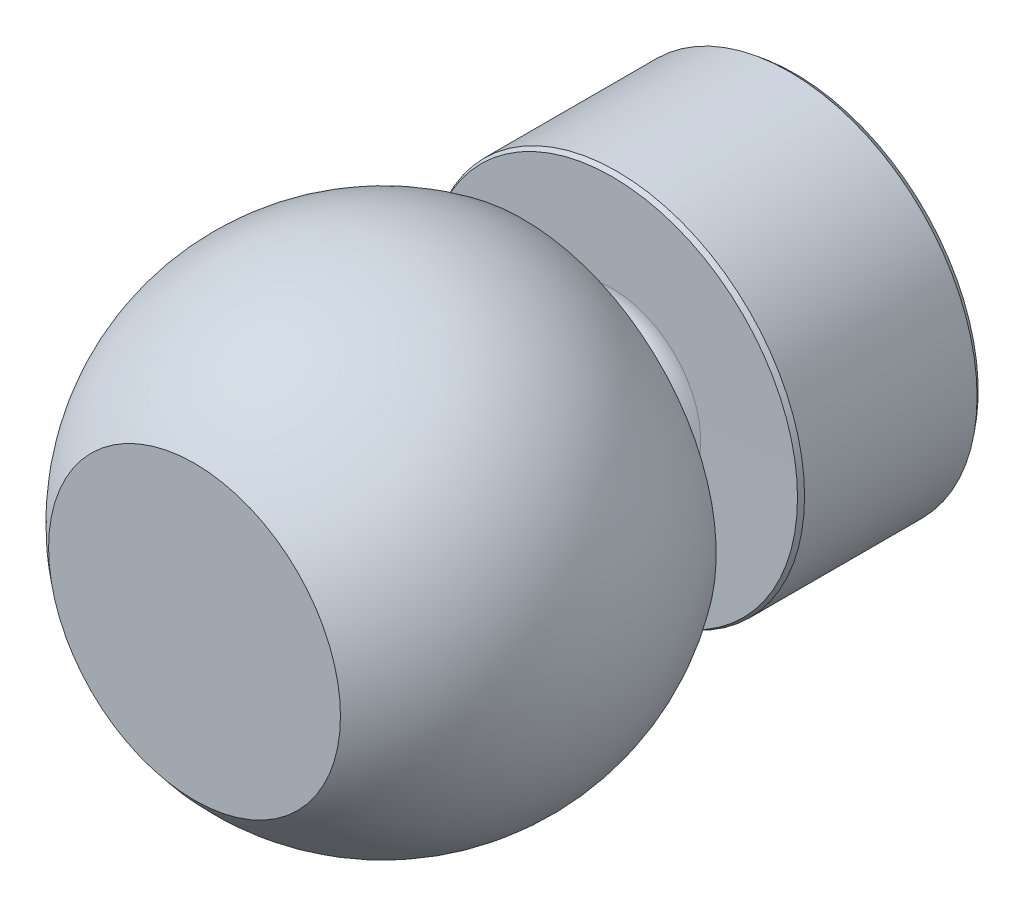
from build123d import *


with BuildPart() as part:
    # Sketch1 → Revolve1 (revolve)
    with BuildSketch(Plane(origin=(0, 0, 0), x_dir=(1, 0, 0), z_dir=(0, 1, 0))):
        with BuildLine():
            Line((18.554185143, -2.529876216), (28.121974873, -2.529876216))
            Line((28.121974873, -2.529876216), (33.621974873, -2.529876216))
            Line((33.621974873, -2.529876216), (34.121974873, -3.147134349))
            Line((34.121974873, -3.147134349), (34.121974873, -16.947673594))
            Line((34.121974873, -16.947673594), (34.121974873, -21.529876216))
            Line((34.121974873, -21.529876216), (33.871974873, -22.029876216))
            Line((33.871974873, -22.029876216), (23.525737468, -21.994577645))
            ThreePointArc((23.525737468, -21.994577645), (21.818442704, -22.783035248), (21.121974873, -24.529876216))
            Line((21.121974873, -24.529876216), (21.121974873, -29.529876216))
            ThreePointArc((21.121974873, -29.529876216), (21.70776131, -30.944089778), (23.121974873, -31.529876216))
            Line((23.121974873, -31.529876216), (23.163890071, -31.529876216))
            Line((23.163890071, -31.529876216), (25.892484704, -31.529876216))
            Line((25.892484704, -31.529876216), (34.707125886, -31.529876216))
            ThreePointArc((34.707125886, -31.529876216), (39.275357094, -50.049169414), (29.672271119, -66.529876216))
            Line((29.672271119, -66.529876216), (19.091113774, -66.529876216))
            Line((19.091113774, -66.529876216), (14.121974873, -66.529876216))
            Line((14.121974873, -66.529876216), (14.121974873, -2.529876216))
            Line((14.121974873, -2.529876216), (18.554185143, -2.529876216))
        make_face()
    revolve(axis=Axis((14.121974873, 0, 2.529876216), (0, 0, 1)))


solid = part.part
